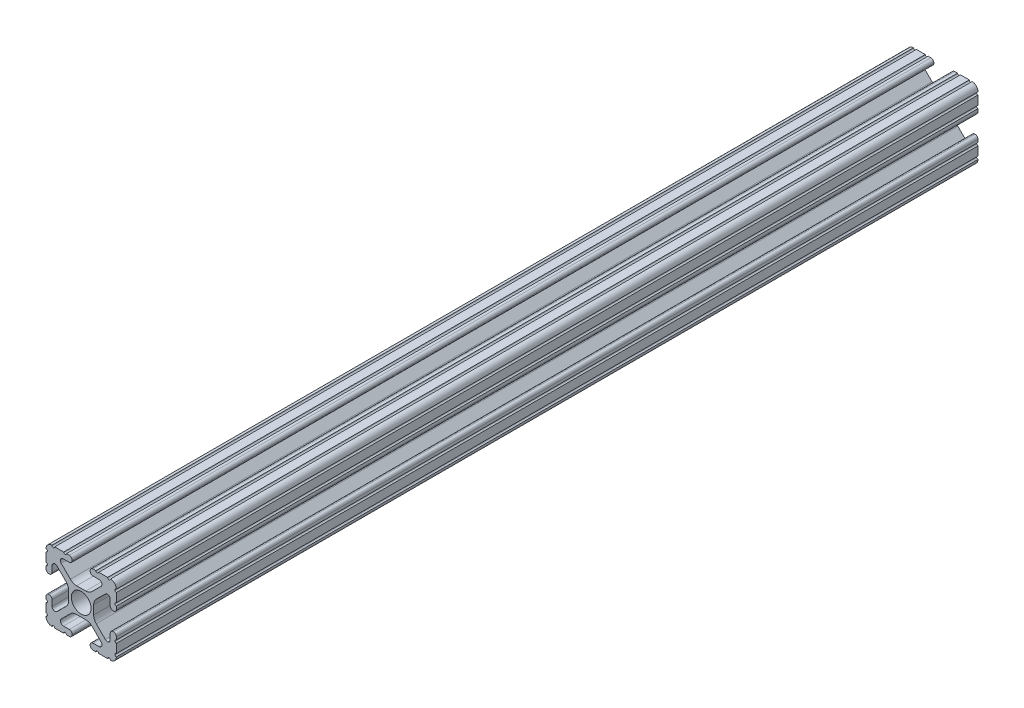
from build123d import *

# Parameters (mm, degrees)
SKETCH1_R           = 3.556
BOSS_EXTRUDE1_DEPTH = 155.575


with BuildPart() as part:
    # Sketch1 → Boss-Extrude1 (new body, symmetric)
    with BuildSketch(Plane.XY):
        with BuildLine():
            Line((-7.179650497, -8.645192506), (-3.952270251, -5.423690499))
            ThreePointArc((-3.952270251, -5.423690499), (-2.922936451, -4.736929036), (-1.709253557, -4.4958))
            Line((-1.709253557, -4.4958), (1.709253557, -4.4958))
            ThreePointArc((1.709253557, -4.4958), (2.922936451, -4.736929036), (3.952270251, -5.423690499))
            Line((3.952270251, -5.423690499), (7.179650497, -8.645192506))
            ThreePointArc((7.179650497, -8.645192506), (7.41473083, -9.822813117), (6.416408329, -10.4902))
            Line((6.416408329, -10.4902), (4.287512407, -10.4902))
            ThreePointArc((4.287512407, -10.4902), (3.54574862, -10.79744862), (3.2385, -11.539212407))
            Line((3.2385, -11.539212407), (3.2385, -11.650987593))
            ThreePointArc((3.2385, -11.650987593), (3.54574862, -12.39275138), (4.287512407, -12.7))
            Line((4.287512407, -12.7), (5.317126718, -12.7))
            ThreePointArc((5.317126718, -12.7), (5.825126718, -12.192), (6.333126718, -12.7))
            Line((6.333126718, -12.7), (9.550443118, -12.7))
            ThreePointArc((9.550443118, -12.7), (10.058366869, -12.192000006), (10.566443095, -12.699847501))
            ThreePointArc((10.566443095, -12.699847501), (12.082537762, -12.08250727), (12.699846982, -10.566399977))
            ThreePointArc((12.699846982, -10.566399977), (12.192000006, -10.058323491), (12.7, -9.5504))
            Line((12.7, -9.5504), (12.7, -6.3330836))
            ThreePointArc((12.7, -6.3330836), (12.192, -5.8250836), (12.7, -5.3170836))
            Line((12.7, -5.3170836), (12.7, -4.287469289))
            ThreePointArc((12.7, -4.287469289), (12.39275138, -3.545705502), (11.650987593, -3.238456882))
            Line((11.650987593, -3.238456882), (11.539212407, -3.238456882))
            ThreePointArc((11.539212407, -3.238456882), (10.79744862, -3.545705502), (10.4902, -4.287469289))
            Line((10.4902, -4.287469289), (10.4902, -6.402089023))
            ThreePointArc((10.4902, -6.402089023), (9.856505071, -7.351067942), (8.737131347, -7.129408934))
            Line((8.737131347, -7.129408934), (5.441005833, -3.840816462))
            ThreePointArc((5.441005833, -3.840816462), (4.750877967, -2.809883091), (4.5085, -1.593185507))
            Line((4.5085, -1.593185507), (4.5085, 1.593185507))
            ThreePointArc((4.5085, 1.593185507), (4.750877967, 2.809883091), (5.441005833, 3.840816462))
            Line((5.441005833, 3.840816462), (8.737131347, 7.129408934))
            ThreePointArc((8.737131347, 7.129408934), (9.856505071, 7.351067942), (10.4902, 6.402089023))
            Line((10.4902, 6.402089023), (10.4902, 4.287469289))
            ThreePointArc((10.4902, 4.287469289), (10.79744862, 3.545705502), (11.539212407, 3.238456882))
            Line((11.539212407, 3.238456882), (11.650987593, 3.238456882))
            ThreePointArc((11.650987593, 3.238456882), (12.39275138, 3.545705502), (12.7, 4.287469289))
            Line((12.7, 4.287469289), (12.7, 5.3170836))
            ThreePointArc((12.7, 5.3170836), (12.192, 5.8250836), (12.7, 6.3330836))
            Line((12.7, 6.3330836), (12.7, 9.5504))
            ThreePointArc((12.7, 9.5504), (12.192000006, 10.058323491), (12.699846982, 10.566399977))
            ThreePointArc((12.699846982, 10.566399977), (12.082537762, 12.08250727), (10.566443095, 12.699847501))
            ThreePointArc((10.566443095, 12.699847501), (10.058366869, 12.192000006), (9.550443118, 12.7))
            Line((9.550443118, 12.7), (6.333126718, 12.7))
            ThreePointArc((6.333126718, 12.7), (5.825126718, 12.192), (5.317126718, 12.7))
            Line((5.317126718, 12.7), (4.287512407, 12.7))
            ThreePointArc((4.287512407, 12.7), (3.54574862, 12.39275138), (3.2385, 11.650987593))
            Line((3.2385, 11.650987593), (3.2385, 11.539212407))
            ThreePointArc((3.2385, 11.539212407), (3.54574862, 10.79744862), (4.287512407, 10.4902))
            Line((4.287512407, 10.4902), (6.476788598, 10.4902))
            ThreePointArc((6.476788598, 10.4902), (7.432222385, 9.85140422), (7.207036008, 8.724370562))
            Line((7.207036008, 8.724370562), (3.898272566, 5.423169045))
            ThreePointArc((3.898272566, 5.423169045), (2.869120213, 4.736787962), (1.655778399, 4.4958))
            Line((1.655778399, 4.4958), (-1.655778399, 4.4958))
            ThreePointArc((-1.655778399, 4.4958), (-2.869120213, 4.736787962), (-3.898272566, 5.423169045))
            Line((-3.898272566, 5.423169045), (-7.207036008, 8.724370562))
            ThreePointArc((-7.207036008, 8.724370562), (-7.432222385, 9.85140422), (-6.476788598, 10.4902))
            Line((-6.476788598, 10.4902), (-4.287512407, 10.4902))
            ThreePointArc((-4.287512407, 10.4902), (-3.54574862, 10.79744862), (-3.2385, 11.539212407))
            Line((-3.2385, 11.539212407), (-3.2385, 11.650987593))
            ThreePointArc((-3.2385, 11.650987593), (-3.54574862, 12.39275138), (-4.287512407, 12.7))
            Line((-4.287512407, 12.7), (-5.317126718, 12.7))
            ThreePointArc((-5.317126718, 12.7), (-5.825126718, 12.192), (-6.333126718, 12.7))
            Line((-6.333126718, 12.7), (-9.550443118, 12.7))
            ThreePointArc((-9.550443118, 12.7), (-10.058366869, 12.192000006), (-10.566443095, 12.699847501))
            ThreePointArc((-10.566443095, 12.699847501), (-12.082537762, 12.08250727), (-12.699846982, 10.566399977))
            ThreePointArc((-12.699846982, 10.566399977), (-12.192000006, 10.058323491), (-12.7, 9.5504))
            Line((-12.7, 9.5504), (-12.7, 6.3330836))
            ThreePointArc((-12.7, 6.3330836), (-12.192, 5.8250836), (-12.7, 5.3170836))
            Line((-12.7, 5.3170836), (-12.7, 4.287469289))
            ThreePointArc((-12.7, 4.287469289), (-12.39275138, 3.545705502), (-11.650987593, 3.238456882))
            Line((-11.650987593, 3.238456882), (-11.539212407, 3.238456882))
            ThreePointArc((-11.539212407, 3.238456882), (-10.79744862, 3.545705502), (-10.4902, 4.287469289))
            Line((-10.4902, 4.287469289), (-10.4902, 6.402089023))
            ThreePointArc((-10.4902, 6.402089023), (-9.856505071, 7.351067942), (-8.737131347, 7.129408934))
            Line((-8.737131347, 7.129408934), (-5.441005833, 3.840816462))
            ThreePointArc((-5.441005833, 3.840816462), (-4.750877967, 2.809883091), (-4.5085, 1.593185507))
            Line((-4.5085, 1.593185507), (-4.5085, -1.593185507))
            ThreePointArc((-4.5085, -1.593185507), (-4.750877967, -2.809883091), (-5.441005833, -3.840816462))
            Line((-5.441005833, -3.840816462), (-8.737131347, -7.129408934))
            ThreePointArc((-8.737131347, -7.129408934), (-9.856505071, -7.351067942), (-10.4902, -6.402089023))
            Line((-10.4902, -6.402089023), (-10.4902, -4.287469289))
            ThreePointArc((-10.4902, -4.287469289), (-10.79744862, -3.545705502), (-11.539212407, -3.238456882))
            Line((-11.539212407, -3.238456882), (-11.650987593, -3.238456882))
            ThreePointArc((-11.650987593, -3.238456882), (-12.39275138, -3.545705502), (-12.7, -4.287469289))
            Line((-12.7, -4.287469289), (-12.7, -5.3170836))
            ThreePointArc((-12.7, -5.3170836), (-12.192, -5.8250836), (-12.7, -6.3330836))
            Line((-12.7, -6.3330836), (-12.7, -9.5504))
            ThreePointArc((-12.7, -9.5504), (-12.192000006, -10.058323491), (-12.699846982, -10.566399977))
            ThreePointArc((-12.699846982, -10.566399977), (-12.082537762, -12.08250727), (-10.566443095, -12.699847501))
            ThreePointArc((-10.566443095, -12.699847501), (-10.058366869, -12.192000006), (-9.550443118, -12.7))
            Line((-9.550443118, -12.7), (-6.333126718, -12.7))
            ThreePointArc((-6.333126718, -12.7), (-5.825126718, -12.192), (-5.317126718, -12.7))
            Line((-5.317126718, -12.7), (-4.287512407, -12.7))
            ThreePointArc((-4.287512407, -12.7), (-3.54574862, -12.39275138), (-3.2385, -11.650987593))
            Line((-3.2385, -11.650987593), (-3.2385, -11.539212407))
            ThreePointArc((-3.2385, -11.539212407), (-3.54574862, -10.79744862), (-4.287512407, -10.4902))
            Line((-4.287512407, -10.4902), (-6.416408329, -10.4902))
            ThreePointArc((-6.416408329, -10.4902), (-7.41473083, -9.822813117), (-7.179650497, -8.645192506))
        make_face()
        Circle(SKETCH1_R, mode=Mode.SUBTRACT)
    extrude(amount=BOSS_EXTRUDE1_DEPTH, both=True)


solid = part.part
